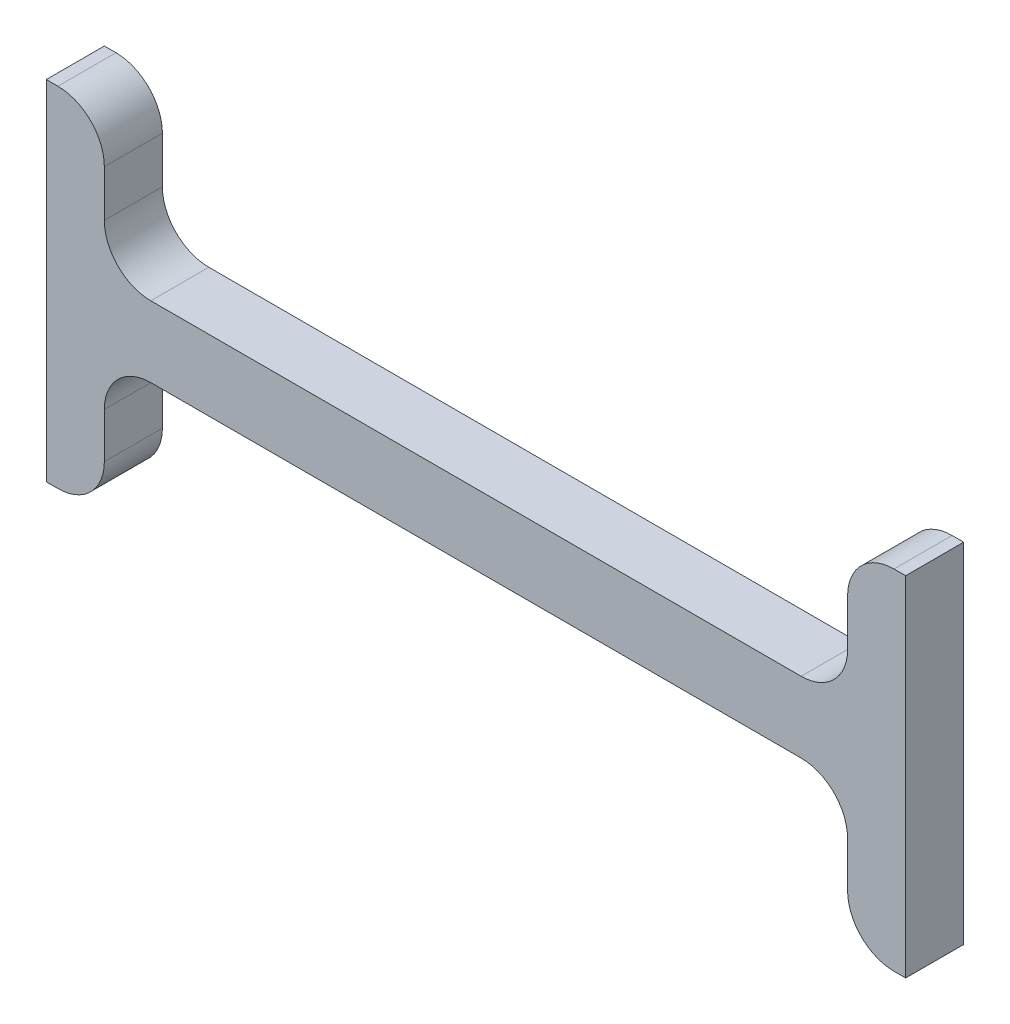
from build123d import *

# Parameters (mm, degrees)
BOSS_EXTRUDE2_DEPTH = 6.35


with BuildPart() as part:
    # Sketch3 → Boss-Extrude2 (new body)
    with BuildSketch(Plane.XY):
        with BuildLine():
            Line((0, 0), (0, 38.1))
            Line((0, 38.1), (1.27, 38.1))
            ThreePointArc((1.27, 38.1), (4.862102448, 36.612102448), (6.35, 33.02))
            Line((6.35, 33.02), (6.35, 27.94))
            ThreePointArc((6.35, 27.94), (7.837897552, 24.347897552), (11.43, 22.86))
            Line((11.43, 22.86), (82.55, 22.86))
            ThreePointArc((82.55, 22.86), (86.142102448, 24.347897552), (87.63, 27.94))
            Line((87.63, 27.94), (87.63, 33.02))
            ThreePointArc((87.63, 33.02), (89.117897552, 36.612102448), (92.71, 38.1))
            Line((92.71, 38.1), (93.98, 38.1))
            Line((93.98, 38.1), (93.98, 0))
            Line((93.98, 0), (92.71, 0))
            ThreePointArc((92.71, 0), (89.117897552, 1.487897552), (87.63, 5.08))
            Line((87.63, 5.08), (87.63, 10.033))
            ThreePointArc((87.63, 10.033), (86.142102448, 13.625102448), (82.55, 15.113))
            Line((82.55, 15.113), (11.43, 15.113))
            ThreePointArc((11.43, 15.113), (7.837897552, 13.625102448), (6.35, 10.033))
            Line((6.35, 10.033), (6.35, 5.08))
            ThreePointArc((6.35, 5.08), (4.862102448, 1.487897552), (1.27, 0))
            Line((1.27, 0), (0, 0))
        make_face()
    extrude(amount=BOSS_EXTRUDE2_DEPTH)


solid = part.part
